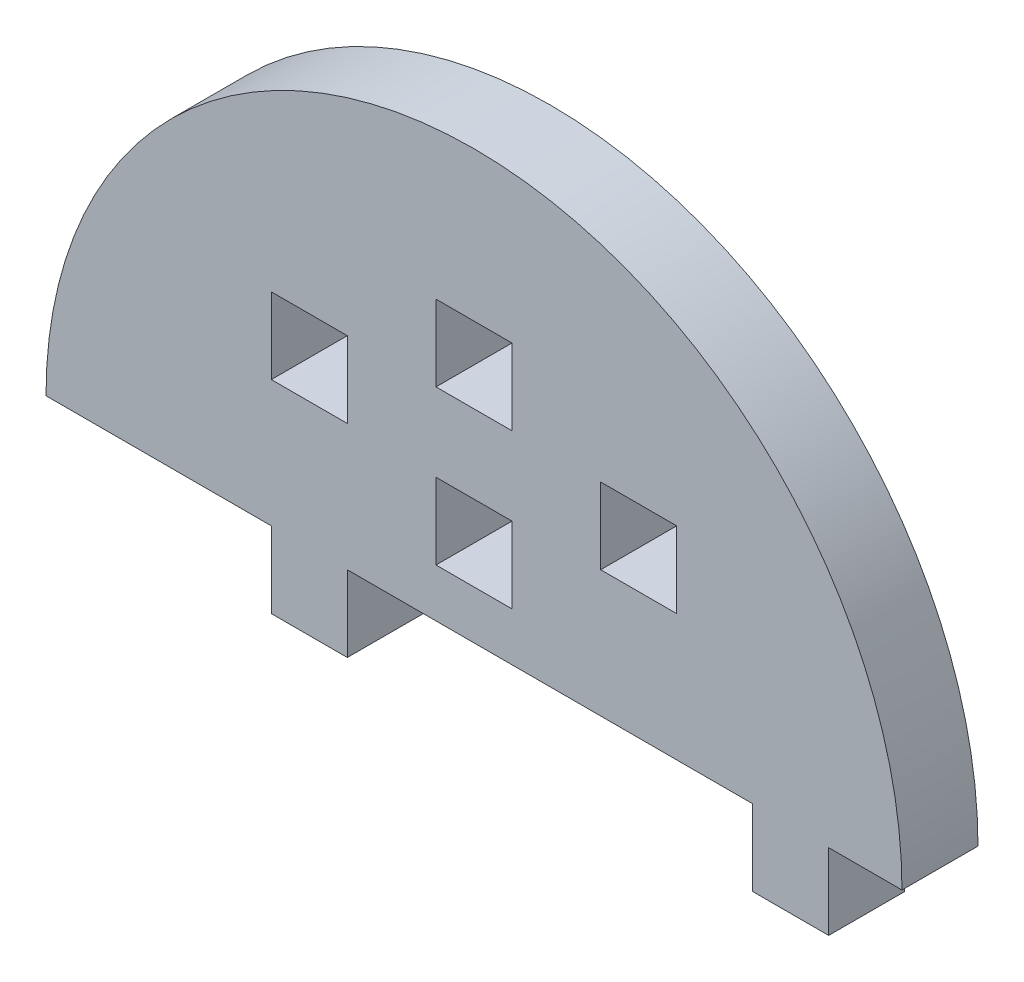
from build123d import *

# Parameters (mm, degrees)
MODEL_W             = 6
MODEL_H             = 6
BOSS_EXTRUDE1_DEPTH = 6


with BuildPart() as part:
    # Model → Boss-Extrude1 (new body)
    with BuildSketch(Plane.XY):
        with BuildLine():
            Line((3970.27341572, 1132.704730077), (3970.27341572, 1126.704730077))
            Line((3970.27341572, 1126.704730077), (3976.27341572, 1126.704730077))
            Line((3976.27341572, 1126.704730077), (3976.27341572, 1132.704730077))
            Line((3976.27341572, 1132.704730077), (3982.059130006, 1132.704730077))
            ThreePointArc((3982.059130006, 1132.704730077), (3948.27341572, 1166.490444363), (3914.487701434, 1132.704730077))
            Line((3914.487701434, 1132.704730077), (3932.27341572, 1132.704730077))
            Line((3932.27341572, 1132.704730077), (3932.27341572, 1126.704730077))
            Line((3932.27341572, 1126.704730077), (3938.27341572, 1126.704730077))
            Line((3938.27341572, 1126.704730077), (3938.27341572, 1132.704730077))
            Line((3938.27341572, 1132.704730077), (3970.27341572, 1132.704730077))
        make_face()
        with Locations((3961.27341572, 1145.704730077)):
            Rectangle(MODEL_W, MODEL_H, mode=Mode.SUBTRACT)
        with Locations((3935.27341572, 1145.704730077)):
            Rectangle(MODEL_W, MODEL_H, mode=Mode.SUBTRACT)
        with Locations((3948.27341572, 1151.704730077)):
            Rectangle(MODEL_W, MODEL_H, mode=Mode.SUBTRACT)
        with Locations((3948.27341572, 1139.529188911)):
            Rectangle(MODEL_W, MODEL_H, mode=Mode.SUBTRACT)
    extrude(amount=BOSS_EXTRUDE1_DEPTH)


solid = part.part
